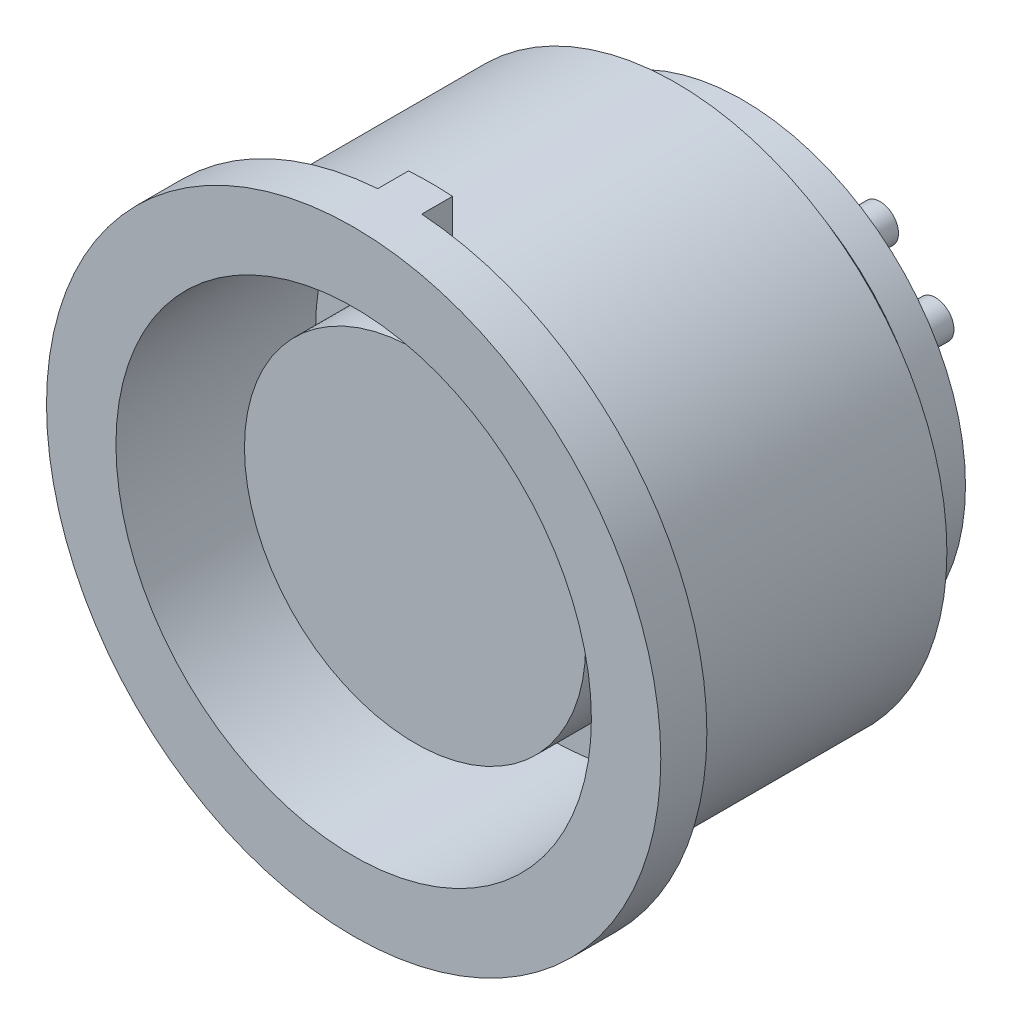
from build123d import *

# Parameters (mm, degrees)
SKETCH3_R           = 0.6
BOSS_EXTRUDE1_DEPTH = 2.5
CIRPATTERN1_COUNT   = 4
BOSS_EXTRUDE2_DEPTH = 1


with BuildPart() as part:
    # Sketch2 → Revolve1 (revolve)
    with BuildSketch(Plane(origin=(0, 0, 0), x_dir=(0, 0, -1), z_dir=(1, 0, 0))):
        Polygon((0, 8.815), (0, 10), (-1.5, 10), (-1.5, 7.74), (5, 7.74), (5, 5.555), (0.5, 5.555), (0.5, 0), (11.17, 0), (11.17, 7.25), (10.130849194, 7.25), (9, 8.815), align=None)
    revolve(axis=Axis((0, 0, 11.357142857), (0, 0, -1)))

    # Sketch3 → Boss-Extrude1 (add)
    with BuildSketch(Plane(origin=(0, 0, -11.17), x_dir=(-1, 0, 0), z_dir=(0, 0, -1))):
        with Locations((1.71395454, 3.773699623)):
            Circle(SKETCH3_R)
        with Locations((1.71395454, 1.968598852)):
            Circle(SKETCH3_R)
        with Locations((3.52115951, 1.968598852)):
            Circle(SKETCH3_R)
    boss_extrude1 = extrude(amount=BOSS_EXTRUDE1_DEPTH)

    # CirPattern1: Boss-Extrude1 ×4 about axis
    cirpattern1_axis = Axis((0, 0, 0), (0, 0, 1))
    for i in range(1, CIRPATTERN1_COUNT):
        add(boss_extrude1.rotate(cirpattern1_axis, i * 360 / CIRPATTERN1_COUNT))

    # Sketch5 → Boss-Extrude2 (add)
    with BuildSketch(Plane(origin=(0, 0, 0), x_dir=(-1, 0, 0), z_dir=(0, 0, -1))):
        with BuildLine():
            Line((-0.71671494, 9.974282916), (-0.71671494, 8.78581497))
            ThreePointArc((-0.71671494, 8.78581497), (0, 8.815), (0.71671494, 8.78581497))
            Line((0.71671494, 8.78581497), (0.71671494, 9.974282916))
            ThreePointArc((0.71671494, 9.974282916), (0, 10), (-0.71671494, 9.974282916))
        make_face()
    extrude(amount=BOSS_EXTRUDE2_DEPTH)


solid = part.part
